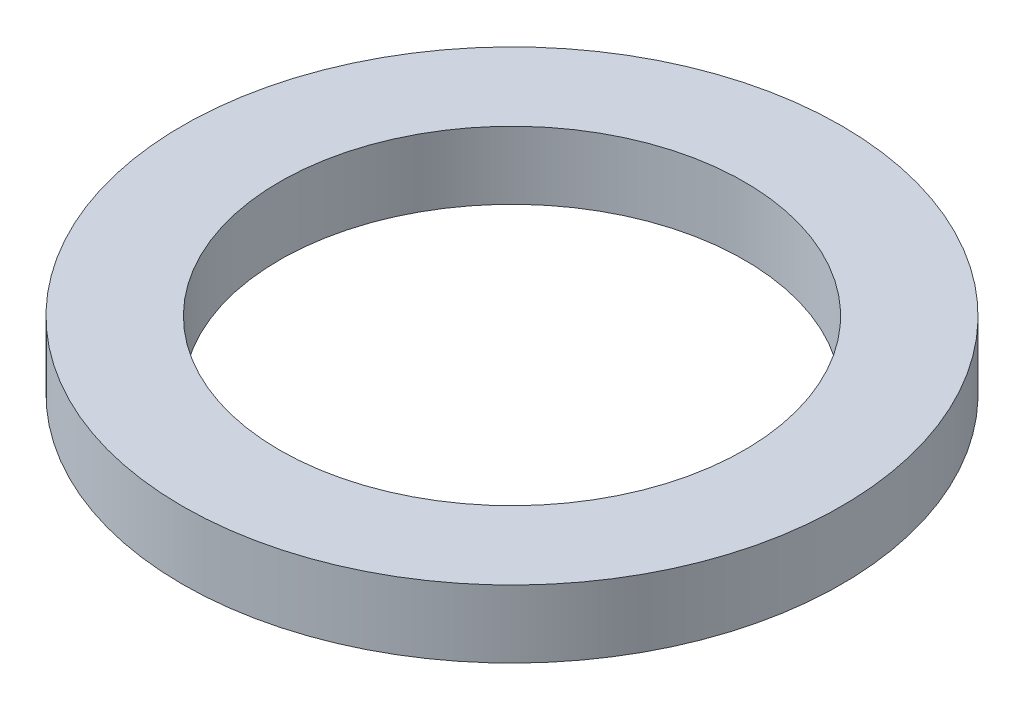
from build123d import *

# Parameters (mm, degrees)
SKETCH1_R           = 3.9
BOSS_EXTRUDE1_DEPTH = 0.8
SKETCH2_R           = 2.75
CUT_EXTRUDE1_DEPTH  = 1.8


with BuildPart() as part:
    # Sketch1 → Boss-Extrude1 (new body)
    with BuildSketch(Plane(origin=(0, 0, 0), x_dir=(1, 0, 0), z_dir=(0, 1, 0))):
        Circle(SKETCH1_R)
    extrude(amount=BOSS_EXTRUDE1_DEPTH)

    # Sketch2 → Cut-Extrude1 (cut, through all)
    with BuildSketch(Plane(origin=(0, 0.8, 0), x_dir=(1, 0, 0), z_dir=(0, 1, 0))):
        Circle(SKETCH2_R)
    extrude(amount=-CUT_EXTRUDE1_DEPTH, mode=Mode.SUBTRACT)


solid = part.part
